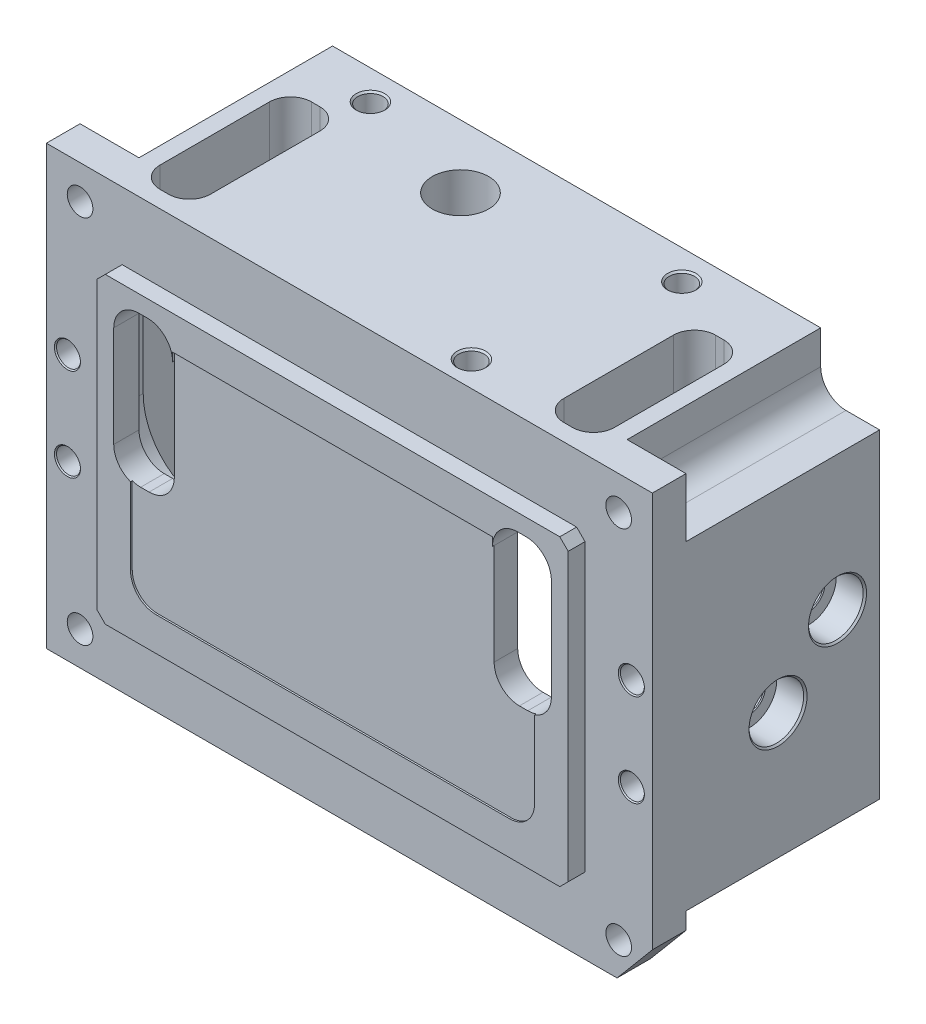
from build123d import *

# Parameters (mm, degrees)
SKETCH_1_W                    = 72
SKETCH_1_H                    = 52
EXTRUDE_1_DEPTH               = 29
HOLE_WIZARD_41_D              = 3.048
HOLE_WIZARD_41_CBORE_D        = 5.08
HOLE_WIZARD_41_CBORE_DEPTH    = 17.5768
CUT_EXTRUDE_1_DEPTH           = 22
CUT_EXTRUDE_15_DEPTH          = 26
CUT_EXTRUDE_2_DEPTH           = 12
HOLE_WIZARD_M31_AT_2_COUNT    = 2
HOLE_WIZARD_M31_AT_2_PITCH    = 9.998489886
HOLE_WIZARD_M32_AT_2_COUNT    = 2
HOLE_WIZARD_M32_AT_2_PITCH    = 9.998489886
HOLE_WIZARD_M3_AT_2_COUNT     = 2
HOLE_WIZARD_M3_AT_2_PITCH     = 37
HOLE_WIZARD_M3_AT_3_COUNT     = 2
HOLE_WIZARD_M3_AT_3_PITCH     = 38.425252114
CUT_EXTRUDE_6_DEPTH           = 54.037722528
SKETCH_29_R                   = 2.54
CUT_EXTRUDE_10_DEPTH          = 23
CHAMFER_1_SIZE                = 5
CHAMFER_1_SIZE2               = 4.195498156
CUT_EXTRUDE_16_DEPTH          = 0.2
SKETCH_31_R                   = 1.524
CUT_EXTRUDE_18_DEPTH          = 2
HOLE_WIZARD_2_4_40_AT_2_COUNT = 2
HOLE_WIZARD_2_4_40_AT_2_PITCH = 11
HOLE_WIZARD_2_4_40_AT_3_COUNT = 2
HOLE_WIZARD_2_4_40_AT_3_PITCH = 67.896980787
HOLE_WIZARD_2_4_40_AT_4_COUNT = 2
HOLE_WIZARD_2_4_40_AT_4_PITCH = 67
SKETCH_32_W                   = 50
SKETCH_32_H                   = 13.538896429
CUT_EXTRUDE_19_DEPTH          = 22
CUT_EXTRUDE_20_REACH          = 71.577
SKETCH_33_R                   = 3.35


with BuildPart() as part:
    # Эскиз1 → Вытянуть1 (new body)
    with BuildSketch(Plane.XY):
        Rectangle(SKETCH_1_W, SKETCH_1_H)
    extrude(amount=EXTRUDE_1_DEPTH)

    # Цековка для  винта с внутренним шестигранником #41 (through all)
    with Locations(Plane(origin=(0, 0, 0), x_dir=(-1, 0, 0), z_dir=(0, 0, -1))):
        with Locations((-32, -22), (-32, 22), (32, 22), (32, -22)):
            CounterBoreHole(HOLE_WIZARD_41_D / 2, HOLE_WIZARD_41_CBORE_D / 2, HOLE_WIZARD_41_CBORE_DEPTH)

    # Эскиз2 → Вырез-Вытянуть1 (cut)
    with BuildSketch(Plane(origin=(0, 0, 0), x_dir=(-1, 0, 0), z_dir=(0, 0, -1))):
        with BuildLine():
            Line((-22.5, -20), (22.5, -20))
            ThreePointArc((22.5, -20), (28.156854249, -17.656854249), (30.5, -12))
            Line((30.5, -12), (30.5, 12))
            ThreePointArc((30.5, 12), (28.156854249, 17.656854249), (22.5, 20))
            Line((22.5, 20), (-22.5, 20))
            ThreePointArc((-22.5, 20), (-28.156854249, 17.656854249), (-30.5, 12))
            Line((-30.5, 12), (-30.5, -12))
            ThreePointArc((-30.5, -12), (-28.156854249, -17.656854249), (-22.5, -20))
        make_face()
    extrude(amount=-CUT_EXTRUDE_1_DEPTH, mode=Mode.SUBTRACT)

    # Эскиз2<3> → Вырез-Вытянуть15 (cut)
    with BuildSketch(Plane(origin=(0, 0, 0), x_dir=(-1, 0, 0), z_dir=(0, 0, -1))):
        with BuildLine():
            Line((-5.5, 1), (-5.5, 12))
            ThreePointArc((-5.5, 12), (-7.843145751, 17.656854249), (-13.5, 20))
            Line((-13.5, 20), (-21.5, 20))
            ThreePointArc((-21.5, 20), (-27.156854249, 17.656854249), (-29.5, 12))
            Line((-29.5, 12), (-29.5, 1))
            ThreePointArc((-29.5, 1), (-27.156854249, -4.656854249), (-21.5, -7))
            Line((-21.5, -7), (-13.5, -7))
            ThreePointArc((-13.5, -7), (-7.843145751, -4.656854249), (-5.5, 1))
        make_face()
        with BuildLine():
            Line((21.5, 20), (13.5, 20))
            ThreePointArc((13.5, 20), (7.843145751, 17.656854249), (5.5, 12))
            Line((5.5, 12), (5.5, 1))
            ThreePointArc((5.5, 1), (7.843145751, -4.656854249), (13.5, -7))
            Line((13.5, -7), (21.5, -7))
            ThreePointArc((21.5, -7), (27.156854249, -4.656854249), (29.5, 1))
            Line((29.5, 1), (29.5, 12))
            ThreePointArc((29.5, 12), (27.156854249, 17.656854249), (21.5, 20))
        make_face()
    extrude(amount=-CUT_EXTRUDE_15_DEPTH, mode=Mode.SUBTRACT)

    # Эскиз3 → Вырез-Вытянуть2 (cut)
    with BuildSketch(Plane(origin=(0, 26, 0), x_dir=(-1, 0, 0), z_dir=(0, 1, 0))):
        with BuildLine():
            Line((-24.5, 25), (-23.5, 25))
            ThreePointArc((-23.5, 25), (-21.732233047, 24.267766953), (-21, 22.5))
            Line((-21, 22.5), (-21, 9.5))
            ThreePointArc((-21, 9.5), (-21.732233047, 7.732233047), (-23.5, 7))
            Line((-23.5, 7), (-24.5, 7))
            ThreePointArc((-24.5, 7), (-26.267766953, 7.732233047), (-27, 9.5))
            Line((-27, 9.5), (-27, 22.5))
            ThreePointArc((-27, 22.5), (-26.267766953, 24.267766953), (-24.5, 25))
        make_face()
        with BuildLine():
            Line((21, 22.5), (21, 9.5))
            ThreePointArc((21, 9.5), (21.732233047, 7.732233047), (23.5, 7))
            Line((23.5, 7), (24.5, 7))
            ThreePointArc((24.5, 7), (26.267766953, 7.732233047), (27, 9.5))
            Line((27, 9.5), (27, 22.5))
            ThreePointArc((27, 22.5), (26.267766953, 24.267766953), (24.5, 25))
            Line((24.5, 25), (23.5, 25))
            ThreePointArc((23.5, 25), (21.732233047, 24.267766953), (21, 22.5))
        make_face()
    extrude(amount=-CUT_EXTRUDE_2_DEPTH, mode=Mode.SUBTRACT)

    # Эскиз8 → Цековка для винта с внутренним шестигранником M31 (revolve, cut)
    with BuildSketch(Plane(origin=(36, 3, 5), x_dir=(0, 0, -1), z_dir=(0, 1, 0))):
        Polygon((0, 0), (0, 5.5), (1.9, 5.5), (1.8, 5.4), (1.8, 3.5), (1.9, 3.4), (3.25, 3.4), (3.25, 0.2), (3.45, 0), align=None)
    hole_wizard_m31 = revolve(axis=Axis((42.35, 3, 5), (-1, 0, 0)), mode=Mode.SUBTRACT)

    # Цековка для винта с внутренним шестигранником M31 at 2: Цековка для винта с внутренним шестигранником M31 ×2
    with Locations(*[Vector(0, -0.7071067811865478, 0.7071067811865475) * (i * HOLE_WIZARD_M31_AT_2_PITCH) for i in range(1, HOLE_WIZARD_M31_AT_2_COUNT)]):
        add(hole_wizard_m31, mode=Mode.SUBTRACT)

    # Эскиз11 → Цековка для винта с внутренним шестигранником M32 (revolve, cut)
    with BuildSketch(Plane(origin=(-36, 0.5, 5), x_dir=(0, 0, 1), z_dir=(0, 1, 0))):
        Polygon((0, 0), (0, 5.5), (1.9, 5.5), (1.8, 5.4), (1.8, 3.5), (1.9, 3.4), (3.25, 3.4), (3.25, 0.2), (3.45, 0), align=None)
    hole_wizard_m32 = revolve(axis=Axis((-42.35, 0.5, 5), (1, 0, 0)), mode=Mode.SUBTRACT)

    # Цековка для винта с внутренним шестигранником M32 at 2: Цековка для винта с внутренним шестигранником M32 ×2
    with Locations(*[Vector(0, -0.7071067811865475, 0.7071067811865476) * (i * HOLE_WIZARD_M32_AT_2_PITCH) for i in range(1, HOLE_WIZARD_M32_AT_2_COUNT)]):
        add(hole_wizard_m32, mode=Mode.SUBTRACT)

    # Эскиз18 → Hole Wizard M3 (revolve, cut)
    with BuildSketch(Plane(origin=(-21, 26, 3.5), x_dir=(0, 0, 1), z_dir=(1, 0, 0))):
        Polygon((0, 0), (0, 10.751075774), (1.25, 10), (1.25, 8), (1.5, 8), (1.5, 0.2), (1.7, 0), align=None)
    hole_wizard_m3 = revolve(axis=Axis((-21, 32.35, 3.5), (0, -1, 0)), mode=Mode.SUBTRACT)

    # Hole Wizard M3 at 2: Hole Wizard M3 ×2
    with Locations(*[(i * HOLE_WIZARD_M3_AT_2_PITCH, 0, 0) for i in range(1, HOLE_WIZARD_M3_AT_2_COUNT)]):
        add(hole_wizard_m3, mode=Mode.SUBTRACT)

    # Hole Wizard M3 at 3: Hole Wizard M3 ×2
    with Locations(*[Vector(0.8457979638974977, 0, 0.5335033310738061) * (i * HOLE_WIZARD_M3_AT_3_PITCH) for i in range(1, HOLE_WIZARD_M3_AT_3_COUNT)]):
        add(hole_wizard_m3, mode=Mode.SUBTRACT)

    # Эскиз22 → Вырез-Вытянуть6 (cut, through all)
    with BuildSketch(Plane.XY.offset(29)):
        with BuildLine():
            Line((-22, -2), (-23, -2))
            ThreePointArc((-23, -2), (-25.121320344, -1.121320344), (-26, 1))
            Line((-26, 1), (-26, 13))
            ThreePointArc((-26, 13), (-25.121320344, 15.121320344), (-23, 16))
            Line((-23, 16), (-22, 16))
            ThreePointArc((-22, 16), (-19.878679656, 15.121320344), (-19, 13))
            Line((-19, 13), (-19, 1))
            ThreePointArc((-19, 1), (-19.878679656, -1.121320344), (-22, -2))
        make_face()
        with BuildLine():
            Line((22, -2), (23, -2))
            ThreePointArc((23, -2), (25.121320344, -1.121320344), (26, 1))
            Line((26, 1), (26, 13))
            ThreePointArc((26, 13), (25.121320344, 15.121320344), (23, 16))
            Line((23, 16), (22, 16))
            ThreePointArc((22, 16), (19.878679656, 15.121320344), (19, 13))
            Line((19, 13), (19, 1))
            ThreePointArc((19, 1), (19.878679656, -1.121320344), (22, -2))
        make_face()
    extrude(amount=-CUT_EXTRUDE_6_DEPTH, mode=Mode.SUBTRACT)

    # Эскиз29 → Вырез-Вытянуть10 (cut)
    with BuildSketch(Plane(origin=(0, 0, 0), x_dir=(-1, 0, 0), z_dir=(0, 0, -1))):
        with BuildLine():
            Line((-29, 22), (-29, 26))
            Line((-29, 26), (-36, 26))
            Line((-36, 26), (-36, 19))
            Line((-36, 19), (-32, 19))
            ThreePointArc((-32, 19), (-29.878679656, 19.878679656), (-29, 22))
        make_face()
        with Locations((-32, 22)):
            Circle(SKETCH_29_R, mode=Mode.SUBTRACT)
        with BuildLine():
            Line((36, 26), (29, 26))
            Line((29, 26), (29, 22))
            ThreePointArc((29, 22), (29.878679656, 19.878679656), (32, 19))
            Line((32, 19), (36, 19))
            Line((36, 19), (36, 26))
        make_face()
        with Locations((32, 22)):
            Circle(SKETCH_29_R, mode=Mode.SUBTRACT)
        with BuildLine():
            Line((-32, -19), (-36, -19))
            Line((-36, -19), (-36, -26))
            Line((-36, -26), (-29, -26))
            Line((-29, -26), (-29, -22))
            ThreePointArc((-29, -22), (-29.878679656, -19.878679656), (-32, -19))
        make_face()
        with Locations((-32, -22)):
            Circle(SKETCH_29_R, mode=Mode.SUBTRACT)
        with BuildLine():
            Line((36, -26), (36, -19))
            Line((36, -19), (32, -19))
            ThreePointArc((32, -19), (29.878679656, -19.878679656), (29, -22))
            Line((29, -22), (29, -26))
            Line((29, -26), (36, -26))
        make_face()
        with Locations((32, -22)):
            Circle(SKETCH_29_R, mode=Mode.SUBTRACT)
        with Locations((-32, 22)):
            Circle(SKETCH_29_R)
        with Locations((32, 22)):
            Circle(SKETCH_29_R)
        with Locations((32, -22)):
            Circle(SKETCH_29_R)
        with Locations((-32, -22)):
            Circle(SKETCH_29_R)
    extrude(amount=-CUT_EXTRUDE_10_DEPTH, mode=Mode.SUBTRACT)

    # Фаска1
    chamfer_1_edges = [part.edges().sort_by_distance(p)[0] for p in [
        (36, -26, 26),
    ]]
    chamfer_1_side = [part.faces().sort_by_distance(p)[0] for p in [
        (36, 0.036005926, 15.770768448),
    ]]
    chamfer(chamfer_1_edges, length=CHAMFER_1_SIZE, length2=CHAMFER_1_SIZE2, reference=chamfer_1_side[0])

    # Эскиз30 → Вырез-Вытянуть16 (cut)
    with BuildSketch(Plane.XY.offset(29)):
        with BuildLine():
            Line((0, 14), (-19, 14))
            Line((-19, 14), (-19, 1))
            ThreePointArc((-19, 1), (-19.878679656, -1.121320344), (-22, -2))
            Line((-22, -2), (-23, -2))
            ThreePointArc((-23, -2), (-23.507305936, -1.956795679), (-24, -1.828427125))
            Line((-24, -1.828427125), (-24, -11))
            ThreePointArc((-24, -11), (-23.121320344, -13.121320344), (-21, -14))
            Line((-21, -14), (21, -14))
            ThreePointArc((21, -14), (23.121320344, -13.121320344), (24, -11))
            Line((24, -11), (24, -1.828427125))
            ThreePointArc((24, -1.828427125), (23.507305936, -1.956795679), (23, -2))
            Line((23, -2), (22, -2))
            ThreePointArc((22, -2), (19.878679656, -1.121320344), (19, 1))
            Line((19, 1), (19, 14))
            Line((19, 14), (0, 14))
        make_face()
    extrude(amount=-CUT_EXTRUDE_16_DEPTH, mode=Mode.SUBTRACT)

    # Эскиз31 → Вырез-Вытянуть18 (cut)
    with BuildSketch(Plane.XY.offset(29)):
        Polygon((-36, 26), (-36, -26), (31.804501844, -26), (36, -21), (36, 26), align=None)
        with Locations(Location((-32, -22, 0), (0, 0, 180))):
            Circle(SKETCH_31_R, mode=Mode.SUBTRACT)
        with Locations(Location((32, -22, 0), (0, 0, 180))):
            Circle(SKETCH_31_R, mode=Mode.SUBTRACT)
        Polygon((-28, -17), (-28, 17), (-27, 18), (27, 18), (28, 17), (28, -17), (27, -18), (-27, -18), align=None, mode=Mode.SUBTRACT)
        with Locations(Location((-32, 22, 0), (0, 0, 180))):
            Circle(SKETCH_31_R, mode=Mode.SUBTRACT)
        with Locations(Location((32, 22, 0), (0, 0, 180))):
            Circle(SKETCH_31_R, mode=Mode.SUBTRACT)
    extrude(amount=-CUT_EXTRUDE_18_DEPTH, mode=Mode.SUBTRACT)

    # Эскиз27 → 2 Отверстие #4-40 (revolve, cut)
    with BuildSketch(Plane(origin=(33.5, -5.5, 27), x_dir=(0, -1, 0), z_dir=(1, 0, 0))):
        Polygon((0, 0), (0, 9.539152758), (1.1303, 8.86), (1.1303, 5.69), (1.4224, 5.69), (1.4224, 0.127), (1.5494, 0), align=None)
    hole_wizard_2_4_40 = revolve(axis=Axis((33.5, -5.5, 33.35), (0, 0, -1)), mode=Mode.SUBTRACT)

    # 2 Отверстие #4-40 at 2: 2 Отверстие #4-40 ×2
    with Locations(*[(0, i * HOLE_WIZARD_2_4_40_AT_2_PITCH, 0) for i in range(1, HOLE_WIZARD_2_4_40_AT_2_COUNT)]):
        add(hole_wizard_2_4_40, mode=Mode.SUBTRACT)

    # 2 Отверстие #4-40 at 3: 2 Отверстие #4-40 ×2
    with Locations(*[Vector(-0.9867890916993085, 0.16201014938346858, 0) * (i * HOLE_WIZARD_2_4_40_AT_3_PITCH) for i in range(1, HOLE_WIZARD_2_4_40_AT_3_COUNT)]):
        add(hole_wizard_2_4_40, mode=Mode.SUBTRACT)

    # 2 Отверстие #4-40 at 4: 2 Отверстие #4-40 ×2
    with Locations(*[(-i * HOLE_WIZARD_2_4_40_AT_4_PITCH, 0, 0) for i in range(1, HOLE_WIZARD_2_4_40_AT_4_COUNT)]):
        add(hole_wizard_2_4_40, mode=Mode.SUBTRACT)

    # Эскиз32 → Вырез-Вытянуть19 (cut)
    with BuildSketch(Plane(origin=(0, 0, 0), x_dir=(-1, 0, 0), z_dir=(0, 0, -1))):
        with Locations((0.045241777, -21.859305191)):
            Rectangle(SKETCH_32_W, SKETCH_32_H)
    extrude(amount=-CUT_EXTRUDE_19_DEPTH, mode=Mode.SUBTRACT)

    # Эскиз33 → Вырез-Вытянуть20 (cut, up to next)
    with BuildSketch(Plane(origin=(0, 26, 0), x_dir=(1, 0, 0), z_dir=(0, 1, 0)), mode=Mode.PRIVATE) as cut_extrude_20_sk1:
        with Locations(Location((-6.3, -7.5, 0), (0, 0, 270))):
            Circle(SKETCH_33_R)
    cut_extrude_20_tool1 = extrude(cut_extrude_20_sk1.sketch, amount=-CUT_EXTRUDE_20_REACH, mode=Mode.PRIVATE) & part.part
    add(cut_extrude_20_tool1.solids().sort_by_distance((-6.3, 26, 7.5))[0], mode=Mode.SUBTRACT)


solid = part.part
